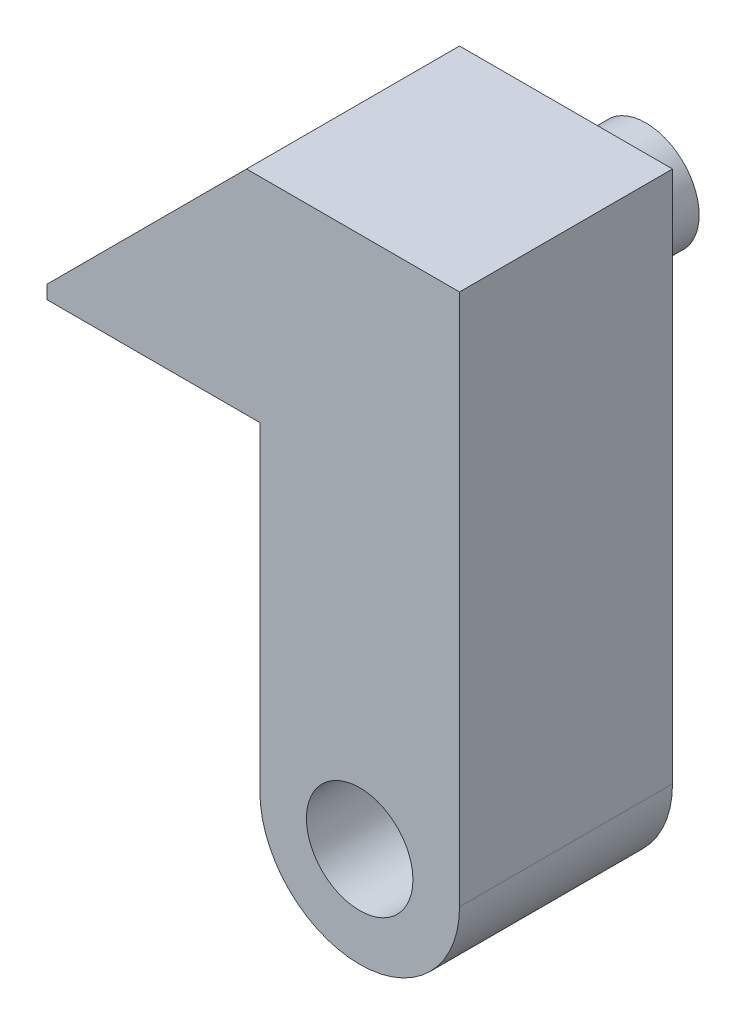
from build123d import *

# Parameters (mm, degrees)
SKETCH1_R           = 3.175
BOSS_EXTRUDE1_DEPTH = 12.7
SKETCH2_R           = 3.175
BOSS_EXTRUDE2_DEPTH = 4.7625
SKETCH3_W           = 1.5875
SKETCH3_H           = 0.79375
CUT_EXTRUDE1_DEPTH  = 9.525


with BuildPart() as part:
    # Sketch1 → Boss-Extrude1 (new body)
    with BuildSketch(Plane.XY):
        with BuildLine():
            Line((0, 0), (0, 19.05))
            Line((0, 19.05), (-12.7, 19.05))
            Line((-12.7, 19.05), (-12.7, 19.84375))
            Line((-12.7, 19.84375), (-0.79375, 31.75))
            Line((-0.79375, 31.75), (11.90625, 31.75))
            Line((11.90625, 31.75), (11.90625, 0))
            ThreePointArc((11.90625, 0), (5.953125, -5.953125), (0, 0))
        make_face()
        with Locations((5.953125, 0)):
            Circle(SKETCH1_R, mode=Mode.SUBTRACT)
    extrude(amount=BOSS_EXTRUDE1_DEPTH)

    # Sketch2 → Boss-Extrude2 (add)
    with BuildSketch(Plane(origin=(0, 0, 0), x_dir=(-1, 0, 0), z_dir=(0, 0, -1))):
        with Locations((-5.55625, 25.4)):
            Circle(SKETCH2_R)
    extrude(amount=BOSS_EXTRUDE2_DEPTH)

    # Sketch3 → Cut-Extrude1 (cut)
    with BuildSketch(Plane(origin=(-12.16693903, 12.16693903, 0), x_dir=(0, 0, 1), z_dir=(-0.707106781, 0.707106781, 0))):
        with Locations((-2.38125, 24.667499295)):
            Rectangle(SKETCH3_W, SKETCH3_H)
    extrude(amount=-CUT_EXTRUDE1_DEPTH, mode=Mode.SUBTRACT)


solid = part.part
